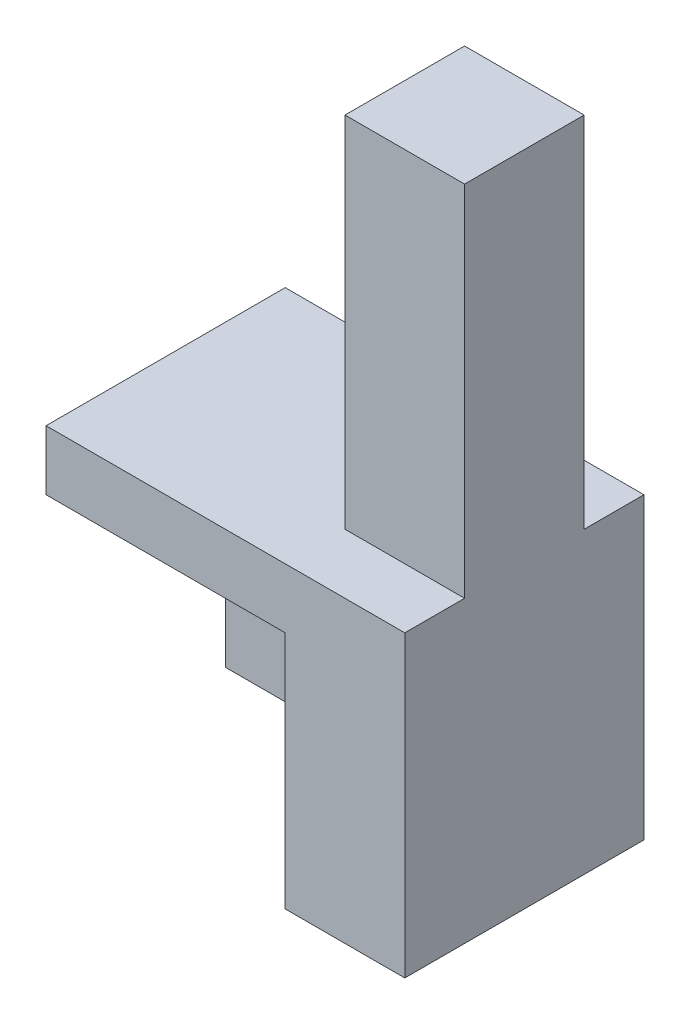
from build123d import *

# Parameters (mm, degrees)
BOSS_EXTRUDE3_DEPTH = 10
SKETCH4_W           = 30
SKETCH4_H           = 25
BOSS_EXTRUDE4_DEPTH = 5
BOSS_EXTRUDE5_DEPTH = 5


with BuildPart() as part:
    # Sketch3 → Boss-Extrude3 (new body)
    with BuildSketch(Plane.XY):
        Polygon((0, 0), (0, -5), (20, -5), (20, -25), (30, -25), (30, 30), (20, 30), (20, 0), align=None)
    extrude(amount=BOSS_EXTRUDE3_DEPTH)

    # Sketch4 → Boss-Extrude4 (add)
    with BuildSketch(Plane(origin=(0, 0, 0), x_dir=(-1, 0, 0), z_dir=(0, 0, -1))):
        with Locations((-15, -12.5)):
            Rectangle(SKETCH4_W, SKETCH4_H)
    extrude(amount=BOSS_EXTRUDE4_DEPTH)

    # Sketch5 → Boss-Extrude5 (add)
    with BuildSketch(Plane.XY.offset(10)):
        Polygon((0, 0), (0, -5), (20, -5), (20, -25), (30, -25), (30, 0), align=None)
    extrude(amount=BOSS_EXTRUDE5_DEPTH)


solid = part.part
